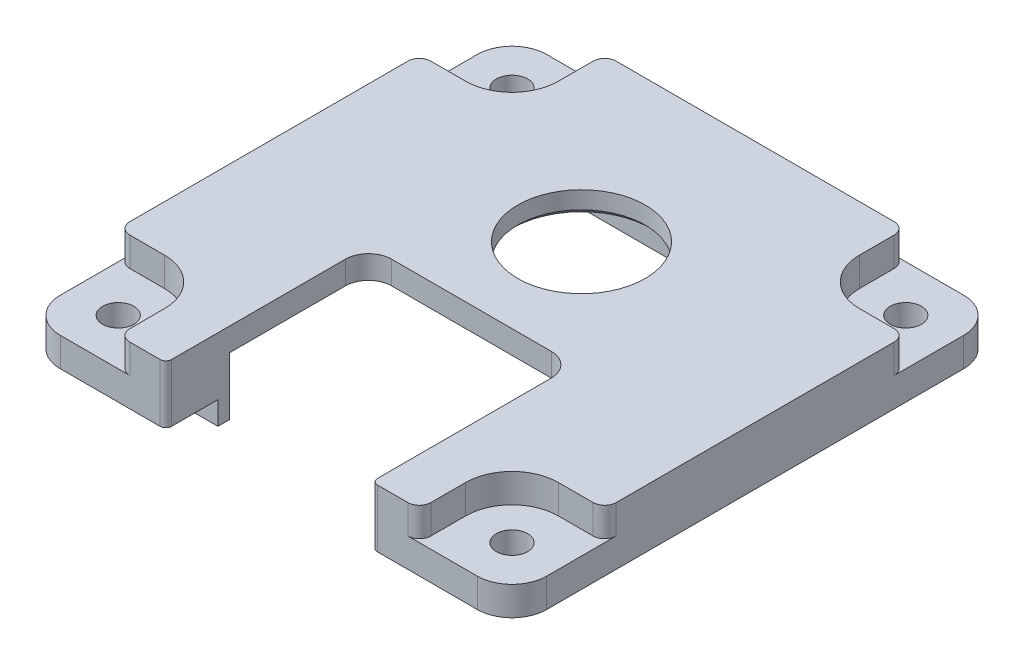
from build123d import *

# Parameters (mm, degrees)
SKETCH2_W           = 42
SKETCH2_H           = 42
SKETCH2_R           = 5.5
BOSS_EXTRUDE1_DEPTH = 2
SKETCH4_W           = 42
SKETCH4_H           = 42
BOSS_EXTRUDE2_DEPTH = 3
BOSS_EXTRUDE3_DEPTH = 3
BOSS_EXTRUDE5_DEPTH = 5
CUT_EXTRUDE1_DEPTH  = 2.5
SKETCH9_R           = 1.35
CUT_EXTRUDE2_DEPTH  = 8
FILLET1_R           = 3
FILLET2_R           = 1
CHAMFER1_SIZE       = 0.5
SKETCH11_W          = 17.78
SKETCH11_H          = 17.5
CUT_EXTRUDE3_DEPTH  = 7
FILLET3_R           = 2
FILLET4_R           = 0.5


with BuildPart() as part:
    # Sketch2 → Boss-Extrude1 (new body)
    with BuildSketch(Plane(origin=(0, 0, 0), x_dir=(1, 0, 0), z_dir=(0, 1, 0))):
        Rectangle(SKETCH2_W, SKETCH2_H)
        with Locations((0, 6)):
            Circle(SKETCH2_R, mode=Mode.SUBTRACT)
    extrude(amount=-BOSS_EXTRUDE1_DEPTH)

    # Sketch4 → Boss-Extrude2 (add)
    with BuildSketch(Plane.XZ.offset(2)):
        Rectangle(SKETCH4_W, SKETCH4_H)
        with BuildLine():
            Line((-17, 11.522774425), (-17, -11.522774425))
            ThreePointArc((-17, -11.522774425), (-16.869274473, -11.859874356), (-16.545454545, -12.020704023))
            ThreePointArc((-16.545454545, -12.020704023), (-13.464466094, -13.464466094), (-12.020704023, -16.545454545))
            ThreePointArc((-12.020704023, -16.545454545), (-11.859874356, -16.869274473), (-11.522774425, -17))
            Line((-11.522774425, -17), (11.522774425, -17))
            ThreePointArc((11.522774425, -17), (11.859874356, -16.869274473), (12.020704023, -16.545454545))
            ThreePointArc((12.020704023, -16.545454545), (13.464466094, -13.464466094), (16.545454545, -12.020704023))
            ThreePointArc((16.545454545, -12.020704023), (16.869274473, -11.859874356), (17, -11.522774425))
            Line((17, -11.522774425), (17, 11.522774425))
            ThreePointArc((17, 11.522774425), (16.869274473, 11.859874356), (16.545454545, 12.020704023))
            ThreePointArc((16.545454545, 12.020704023), (13.464466094, 13.464466094), (12.020704023, 16.545454545))
            ThreePointArc((12.020704023, 16.545454545), (11.859874356, 16.869274473), (11.522774425, 17))
            Line((11.522774425, 17), (-11.522774425, 17))
            ThreePointArc((-11.522774425, 17), (-11.859874356, 16.869274473), (-12.020704023, 16.545454545))
            ThreePointArc((-12.020704023, 16.545454545), (-13.464466094, 13.464466094), (-16.545454545, 12.020704023))
            ThreePointArc((-16.545454545, 12.020704023), (-16.869274473, 11.859874356), (-17, 11.522774425))
        make_face(mode=Mode.SUBTRACT)
    extrude(amount=BOSS_EXTRUDE2_DEPTH)

    # Sketch6 → Boss-Extrude3 (add)
    with BuildSketch(Plane.XZ.offset(2)):
        with BuildLine():
            Line((-17, 11.522774425), (-17, -11.522774425))
            ThreePointArc((-17, -11.522774425), (-16.869274473, -11.859874356), (-16.545454545, -12.020704023))
            ThreePointArc((-16.545454545, -12.020704023), (-13.464466094, -13.464466094), (-12.020704023, -16.545454545))
            ThreePointArc((-12.020704023, -16.545454545), (-11.859874356, -16.869274473), (-11.522774425, -17))
            Line((-11.522774425, -17), (11.522774425, -17))
            ThreePointArc((11.522774425, -17), (11.859874356, -16.869274473), (12.020704023, -16.545454545))
            ThreePointArc((12.020704023, -16.545454545), (13.464466094, -13.464466094), (16.545454545, -12.020704023))
            ThreePointArc((16.545454545, -12.020704023), (16.869274473, -11.859874356), (17, -11.522774425))
            Line((17, -11.522774425), (17, 11.522774425))
            ThreePointArc((17, 11.522774425), (16.869274473, 11.859874356), (16.545454545, 12.020704023))
            ThreePointArc((16.545454545, 12.020704023), (13.464466094, 13.464466094), (12.020704023, 16.545454545))
            ThreePointArc((12.020704023, 16.545454545), (11.859874356, 16.869274473), (11.522774425, 17))
            Line((11.522774425, 17), (-11.522774425, 17))
            ThreePointArc((-11.522774425, 17), (-11.859874356, 16.869274473), (-12.020704023, 16.545454545))
            ThreePointArc((-12.020704023, 16.545454545), (-13.464466094, 13.464466094), (-16.545454545, 12.020704023))
            ThreePointArc((-16.545454545, 12.020704023), (-16.869274473, 11.859874356), (-17, 11.522774425))
        make_face()
        with BuildLine():
            Line((-16.5, 11.522774425), (-16.5, -11.522774425))
            ThreePointArc((-16.5, -11.522774425), (-13.110912703, -13.110912703), (-11.522774425, -16.5))
            Line((-11.522774425, -16.5), (11.522774425, -16.5))
            ThreePointArc((11.522774425, -16.5), (13.110912703, -13.110912703), (16.5, -11.522774425))
            Line((16.5, -11.522774425), (16.5, 11.522774425))
            ThreePointArc((16.5, 11.522774425), (13.110912703, 13.110912703), (11.522774425, 16.5))
            Line((11.522774425, 16.5), (-11.522774425, 16.5))
            ThreePointArc((-11.522774425, 16.5), (-13.110912703, 13.110912703), (-16.5, 11.522774425))
        make_face(mode=Mode.SUBTRACT)
    extrude(amount=BOSS_EXTRUDE3_DEPTH)

    # Sketch7 → Boss-Extrude5 (add)
    with BuildSketch(Plane.XZ.offset(2)):
        with BuildLine():
            Line((11.522774425, 16.5), (-11.522774425, 16.5))
            ThreePointArc((-11.522774425, 16.5), (-13.110912703, 13.110912703), (-16.5, 11.522774425))
            Line((-16.5, 11.522774425), (-16.5, -11.522774425))
            ThreePointArc((-16.5, -11.522774425), (-13.110912703, -13.110912703), (-11.522774425, -16.5))
            Line((-11.522774425, -16.5), (11.522774425, -16.5))
            ThreePointArc((11.522774425, -16.5), (13.110912703, -13.110912703), (16.5, -11.522774425))
            Line((16.5, -11.522774425), (16.5, 11.522774425))
            ThreePointArc((16.5, 11.522774425), (13.110912703, 13.110912703), (11.522774425, 16.5))
        make_face()
        with BuildLine():
            Line((10.67544468, 15.5), (-10.67544468, 15.5))
            ThreePointArc((-10.67544468, 15.5), (-12.403805922, 12.403805922), (-15.5, 10.67544468))
            Line((-15.5, 10.67544468), (-15.5, -10.67544468))
            ThreePointArc((-15.5, -10.67544468), (-12.403805922, -12.403805922), (-10.67544468, -15.5))
            Line((-10.67544468, -15.5), (10.67544468, -15.5))
            ThreePointArc((10.67544468, -15.5), (12.403805922, -12.403805922), (15.5, -10.67544468))
            Line((15.5, -10.67544468), (15.5, 10.67544468))
            ThreePointArc((15.5, 10.67544468), (12.403805922, 12.403805922), (10.67544468, 15.5))
        make_face(mode=Mode.SUBTRACT)
    extrude(amount=BOSS_EXTRUDE5_DEPTH)

    # Sketch8 → Cut-Extrude1 (cut)
    with BuildSketch(Plane(origin=(0, 0, 0), x_dir=(1, 0, 0), z_dir=(0, 1, 0))):
        with BuildLine():
            Line((-17, 13), (-21, 13))
            Line((-21, 13), (-21, 21))
            Line((-21, 21), (-13, 21))
            Line((-13, 21), (-13, 17))
            ThreePointArc((-13, 17), (-14.171572875, 14.171572875), (-17, 13))
        make_face()
        with BuildLine():
            Line((13, 17), (13, 21))
            Line((13, 21), (21, 21))
            Line((21, 21), (21, 13))
            Line((21, 13), (17, 13))
            ThreePointArc((17, 13), (14.171572875, 14.171572875), (13, 17))
        make_face()
        with BuildLine():
            Line((-21, -17), (-21, -21))
            Line((-21, -21), (-17, -21))
            Line((-17, -21), (-13, -21))
            Line((-13, -21), (-13, -17))
            ThreePointArc((-13, -17), (-14.171572875, -14.171572875), (-17, -13))
            Line((-17, -13), (-21, -13))
            Line((-21, -13), (-21, -17))
        make_face()
        with BuildLine():
            Line((17, -13), (21, -13))
            Line((21, -13), (21, -21))
            Line((21, -21), (17, -21))
            Line((17, -21), (13, -21))
            Line((13, -21), (13, -17))
            ThreePointArc((13, -17), (14.171572875, -14.171572875), (17, -13))
        make_face()
    extrude(amount=-CUT_EXTRUDE1_DEPTH, mode=Mode.SUBTRACT)

    # Sketch9 → Cut-Extrude2 (cut, through all)
    with BuildSketch(Plane(origin=(0, 0, 0), x_dir=(1, 0, 0), z_dir=(0, 1, 0))):
        with Locations((-17, 17)):
            Circle(SKETCH9_R)
        with Locations((17, 17)):
            Circle(SKETCH9_R)
        with Locations((-17, -17)):
            Circle(SKETCH9_R)
        with Locations((17, -17)):
            Circle(SKETCH9_R)
    extrude(amount=-CUT_EXTRUDE2_DEPTH, mode=Mode.SUBTRACT)

    # Fillet1
    fillet1_edges = [part.edges().sort_by_distance(p)[0] for p in [
        (21, -3.75, 21),
        (-21, -3.75, 21),
        (-21, -3.75, -21),
        (21, -3.75, -21),
    ]]
    fillet(fillet1_edges, radius=FILLET1_R)

    # Fillet2
    fillet2_edges = [part.edges().sort_by_distance(p)[0] for p in [
        (13, -1.25, -21),
        (21, -1.25, -13),
        (-21, -1.25, 13),
        (-13, -1.25, 21),
        (21, -1.25, 13),
        (13, -1.25, 21),
        (-21, -1.25, -13),
        (-13, -1.25, -21),
    ]]
    fillet(fillet2_edges, radius=FILLET2_R)

    # Chamfer1
    chamfer1_edges = [part.edges().sort_by_distance(p)[0] for p in [
        (-5.5, -2, -6),
    ]]
    chamfer(chamfer1_edges, length=CHAMFER1_SIZE)

    # Sketch11 → Cut-Extrude3 (cut)
    with BuildSketch(Plane(origin=(0, 0, 0), x_dir=(1, 0, 0), z_dir=(0, 1, 0))):
        with Locations((0, -12.25)):
            Rectangle(SKETCH11_W, SKETCH11_H)
    extrude(amount=-CUT_EXTRUDE3_DEPTH, mode=Mode.SUBTRACT)

    # Fillet3
    fillet3_edges = [part.edges().sort_by_distance(p)[0] for p in [
        (-8.89, -1, 3.5),
        (8.89, -1, 3.5),
    ]]
    fillet(fillet3_edges, radius=FILLET3_R)

    # Fillet4
    fillet4_edges = [part.edges().sort_by_distance(p)[0] for p in [
        (-8.89, -2.5, 21),
        (8.89, -2.5, 21),
    ]]
    fillet(fillet4_edges, radius=FILLET4_R)


solid = part.part
